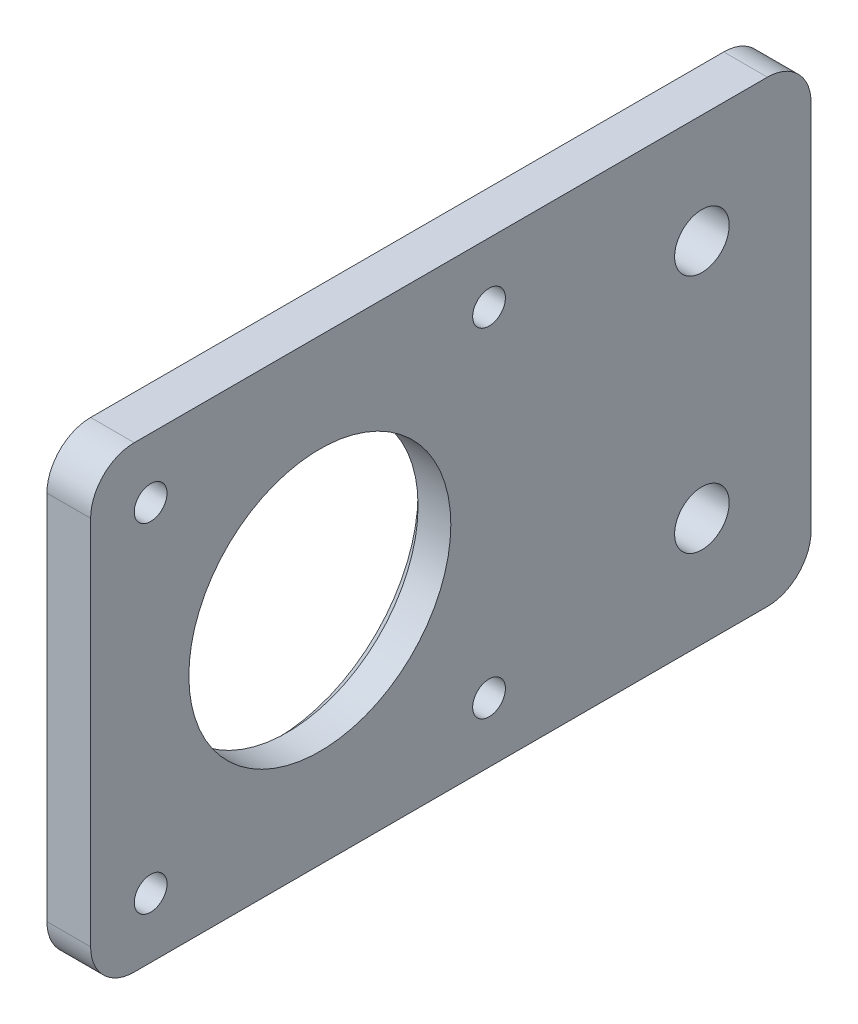
from build123d import *

# Parameters (mm, degrees)
BOSS_EXTRUDE1_DEPTH = 42
SKETCH2_R           = 12
SKETCH2_R_2         = 1.5
CUT_EXTRUDE1_DEPTH  = 5
SKETCH3_R           = 2
CUT_EXTRUDE2_DEPTH  = 5
CHAMFER1_SIZE       = 2
CHAMFER2_SIZE       = 1
FILLET1_R           = 4
BOSS_EXTRUDE2_DEPTH = 42
SKETCH5_W           = 27.168576179
SKETCH5_H           = 4
CUT_EXTRUDE3_DEPTH  = 44
SKETCH6_R           = 2.5
CUT_EXTRUDE4_DEPTH  = 44
FILLET2_R           = 4


with BuildPart() as part:
    # Sketch1 → Boss-Extrude1 (new body)
    with BuildSketch(Plane(origin=(0, 0, 0), x_dir=(1, 0, 0), z_dir=(0, 1, 0))):
        Polygon((0, 0), (0, 42), (-20, 42), (-20, 46), (4, 46), (4, 0), align=None)
    extrude(amount=BOSS_EXTRUDE1_DEPTH)

    # Sketch2 → Cut-Extrude1 (cut, through all)
    with BuildSketch(Plane.ZY):
        with Locations((-21, 21)):
            Circle(SKETCH2_R)
        with Locations((-36.5, 36.5)):
            Circle(SKETCH2_R_2)
        with Locations((-5.5, 36.5)):
            Circle(SKETCH2_R_2)
        with Locations((-5.5, 5.5)):
            Circle(SKETCH2_R_2)
        with Locations((-36.5, 5.5)):
            Circle(SKETCH2_R_2)
    extrude(amount=-CUT_EXTRUDE1_DEPTH, mode=Mode.SUBTRACT)

    # Sketch3 → Cut-Extrude2 (cut, through all)
    with BuildSketch(Plane.XY.offset(-42)):
        with Locations((-10, 32)):
            Circle(SKETCH3_R)
        with Locations((-10, 10)):
            Circle(SKETCH3_R)
    extrude(amount=-CUT_EXTRUDE2_DEPTH, mode=Mode.SUBTRACT)

    # Chamfer1
    chamfer1_edges = [part.edges().sort_by_distance(p)[0] for p in [
        (-12, 32, -42),
        (-12, 10, -42),
    ]]
    chamfer(chamfer1_edges, length=CHAMFER1_SIZE)

    # Chamfer2
    chamfer2_edges = [part.edges().sort_by_distance(p)[0] for p in [
        (0, 21, -33),
    ]]
    chamfer(chamfer2_edges, length=CHAMFER2_SIZE)

    # Fillet1
    fillet1_edges = [part.edges().sort_by_distance(p)[0] for p in [
        (4, 21, -46),
        (-20, 42, -44),
        (2, 42, 0),
        (-20, 0, -44),
        (2, 0, 0),
    ]]
    fillet(fillet1_edges, radius=FILLET1_R)

    # Sketch4 → Boss-Extrude2 (add)
    with BuildSketch(Plane.XZ):
        Polygon((0, -46), (0, -66), (4, -66), (4, -42), (0, -42), align=None)
    extrude(amount=-BOSS_EXTRUDE2_DEPTH)

    # Sketch5 → Cut-Extrude3 (cut)
    with BuildSketch(Plane(origin=(0, 42, 0), x_dir=(1, 0, 0), z_dir=(0, 1, 0))):
        with Locations((-13.58428809, 44)):
            Rectangle(SKETCH5_W, SKETCH5_H)
    extrude(amount=-CUT_EXTRUDE3_DEPTH, mode=Mode.SUBTRACT)

    # Sketch6 → Cut-Extrude4 (cut)
    with BuildSketch(Plane.ZY):
        with Locations((-56, 32)):
            Circle(SKETCH6_R)
        with Locations((-56, 10)):
            Circle(SKETCH6_R)
    extrude(amount=-CUT_EXTRUDE4_DEPTH, mode=Mode.SUBTRACT)

    # Fillet2
    fillet2_edges = [part.edges().sort_by_distance(p)[0] for p in [
        (2, 42, -66),
        (2, 0, -66),
    ]]
    fillet(fillet2_edges, radius=FILLET2_R)


solid = part.part
